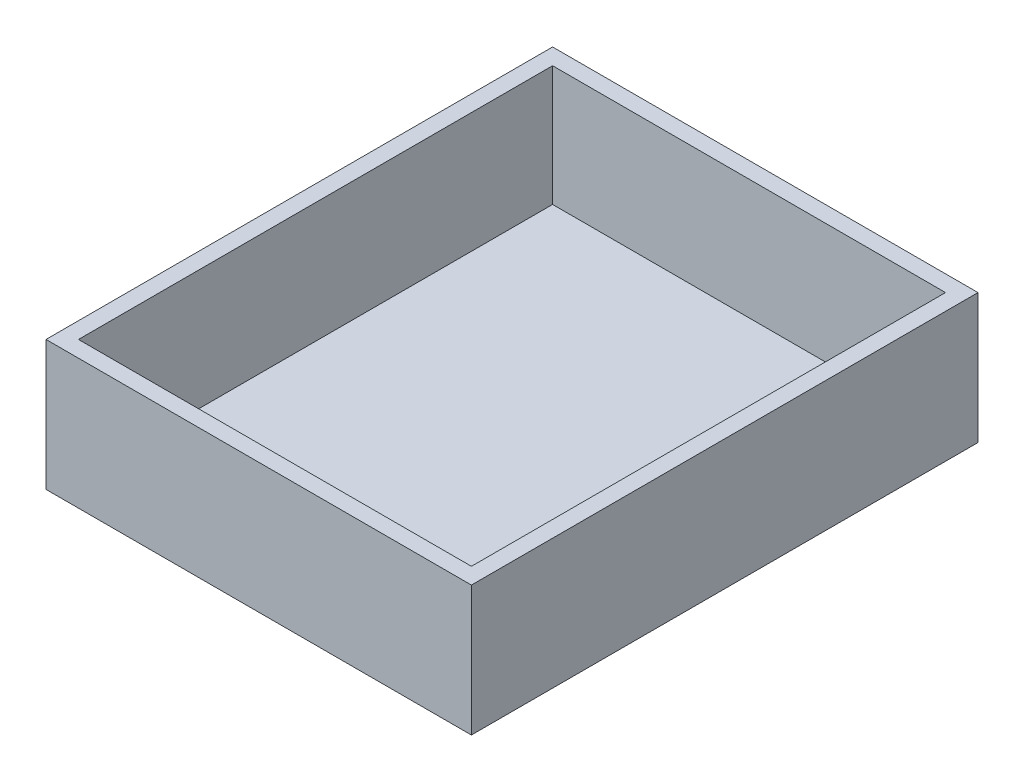
from build123d import *

# Parameters (mm, degrees)
ESBO_O1_W                = 131
ESBO_O1_H                = 156
RESSALTO_EXTRUS_O1_DEPTH = 40
ESBO_O3_W                = 121
ESBO_O3_H                = 146
CORTE_EXTRUS_O1_DEPTH    = 37


with BuildPart() as part:
    # Esboço1 → Ressalto-extrusão1 (new body)
    with BuildSketch(Plane(origin=(0, 0, 0), x_dir=(-1, 0, 0), z_dir=(0, 1, 0))):
        Rectangle(ESBO_O1_W, ESBO_O1_H)
    extrude(amount=RESSALTO_EXTRUS_O1_DEPTH)

    # Esboço3 → Corte-extrusão1 (cut)
    with BuildSketch(Plane(origin=(0, 40, 0), x_dir=(1, 0, 0), z_dir=(0, 1, 0))):
        Rectangle(ESBO_O3_W, ESBO_O3_H)
    extrude(amount=-CORTE_EXTRUS_O1_DEPTH, mode=Mode.SUBTRACT)


solid = part.part
